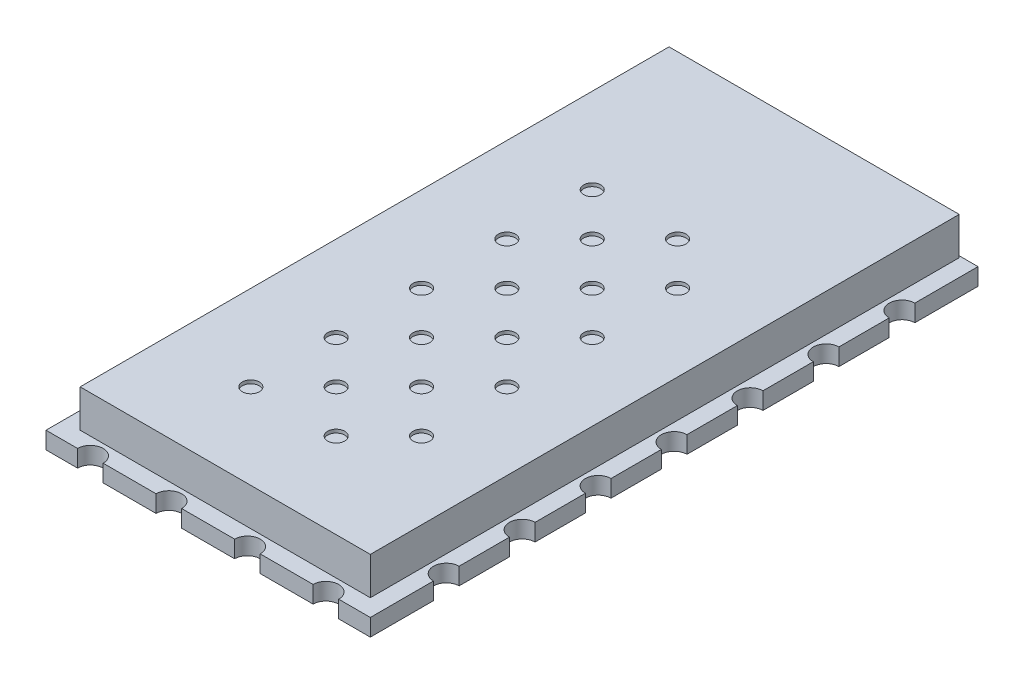
from build123d import *

# Parameters (mm, degrees)
ESQUISSE1_W             = 19
ESQUISSE1_H             = 35.6
BOSS_EXTRU_1_DEPTH      = 1
ESQUISSE2_W             = 17
ESQUISSE2_H             = 34.5
BOSS_EXTRU_2_DEPTH      = 2.2
ESQUISSE3_R             = 0.5
ENL_V_MAT_EXTRU_1_DEPTH = 0.2
ESQUISSE4_R             = 0.75
ENL_V_MAT_EXTRU_2_DEPTH = 2


with BuildPart() as part:
    # Esquisse1 → Boss.-Extru.1 (new body)
    with BuildSketch(Plane(origin=(0, 0, 0), x_dir=(1, 0, 0), z_dir=(0, 1, 0))):
        with Locations((9.5, 17.8)):
            Rectangle(ESQUISSE1_W, ESQUISSE1_H)
    extrude(amount=BOSS_EXTRU_1_DEPTH)

    # Esquisse2 → Boss.-Extru.2 (add)
    with BuildSketch(Plane(origin=(0, 1, 0), x_dir=(1, 0, 0), z_dir=(0, 1, 0))):
        with Locations((9.5, 18.25)):
            Rectangle(ESQUISSE2_W, ESQUISSE2_H)
    extrude(amount=BOSS_EXTRU_2_DEPTH)

    # Esquisse3 → Enlèv. mat.-Extru.1 (cut)
    with BuildSketch(Plane(origin=(0, 3.2, 0), x_dir=(1, 0, 0), z_dir=(0, 1, 0))):
        with Locations((6, 6)):
            Circle(ESQUISSE3_R)
        with Locations((11, 6)):
            Circle(ESQUISSE3_R)
        with Locations((8.5, 8.5)):
            Circle(ESQUISSE3_R)
        with Locations((13.5, 8.5)):
            Circle(ESQUISSE3_R)
        with Locations((11, 11)):
            Circle(ESQUISSE3_R)
        with Locations((8.5, 13.5)):
            Circle(ESQUISSE3_R)
        with Locations((13.5, 13.5)):
            Circle(ESQUISSE3_R)
        with Locations((11, 16)):
            Circle(ESQUISSE3_R)
        with Locations((8.5, 18.5)):
            Circle(ESQUISSE3_R)
        with Locations((13.5, 18.5)):
            Circle(ESQUISSE3_R)
        with Locations((11, 21)):
            Circle(ESQUISSE3_R)
        with Locations((8.5, 23.5)):
            Circle(ESQUISSE3_R)
        with Locations((13.5, 23.5)):
            Circle(ESQUISSE3_R)
        with Locations((11, 26)):
            Circle(ESQUISSE3_R)
        with Locations((6, 11)):
            Circle(ESQUISSE3_R)
        with Locations((6, 16)):
            Circle(ESQUISSE3_R)
        with Locations((6, 21)):
            Circle(ESQUISSE3_R)
        with Locations((6, 26)):
            Circle(ESQUISSE3_R)
    extrude(amount=-ENL_V_MAT_EXTRU_1_DEPTH, mode=Mode.SUBTRACT)

    # Esquisse4 → Enlèv. mat.-Extru.2 (cut, through all)
    with BuildSketch(Plane(origin=(0, 1, 0), x_dir=(1, 0, 0), z_dir=(0, 1, 0))):
        with Locations((2.6, 0)):
            Circle(ESQUISSE4_R)
        with Locations((7.2, 0)):
            Circle(ESQUISSE4_R)
        with Locations((11.8, 0)):
            Circle(ESQUISSE4_R)
        with Locations((16.4, 0)):
            Circle(ESQUISSE4_R)
        with Locations((0, 4.45)):
            Circle(ESQUISSE4_R)
        with Locations((0, 8.9)):
            Circle(ESQUISSE4_R)
        with Locations((0, 13.35)):
            Circle(ESQUISSE4_R)
        with Locations((0, 17.8)):
            Circle(ESQUISSE4_R)
        with Locations((0, 22.25)):
            Circle(ESQUISSE4_R)
        with Locations((0, 26.7)):
            Circle(ESQUISSE4_R)
        with Locations((0, 31.15)):
            Circle(ESQUISSE4_R)
        with Locations((19, 4.45)):
            Circle(ESQUISSE4_R)
        with Locations((19, 8.9)):
            Circle(ESQUISSE4_R)
        with Locations((19, 13.35)):
            Circle(ESQUISSE4_R)
        with Locations((19, 17.8)):
            Circle(ESQUISSE4_R)
        with Locations((19, 22.25)):
            Circle(ESQUISSE4_R)
        with Locations((19, 26.7)):
            Circle(ESQUISSE4_R)
        with Locations((19, 31.15)):
            Circle(ESQUISSE4_R)
    extrude(amount=-ENL_V_MAT_EXTRU_2_DEPTH, mode=Mode.SUBTRACT)


solid = part.part
